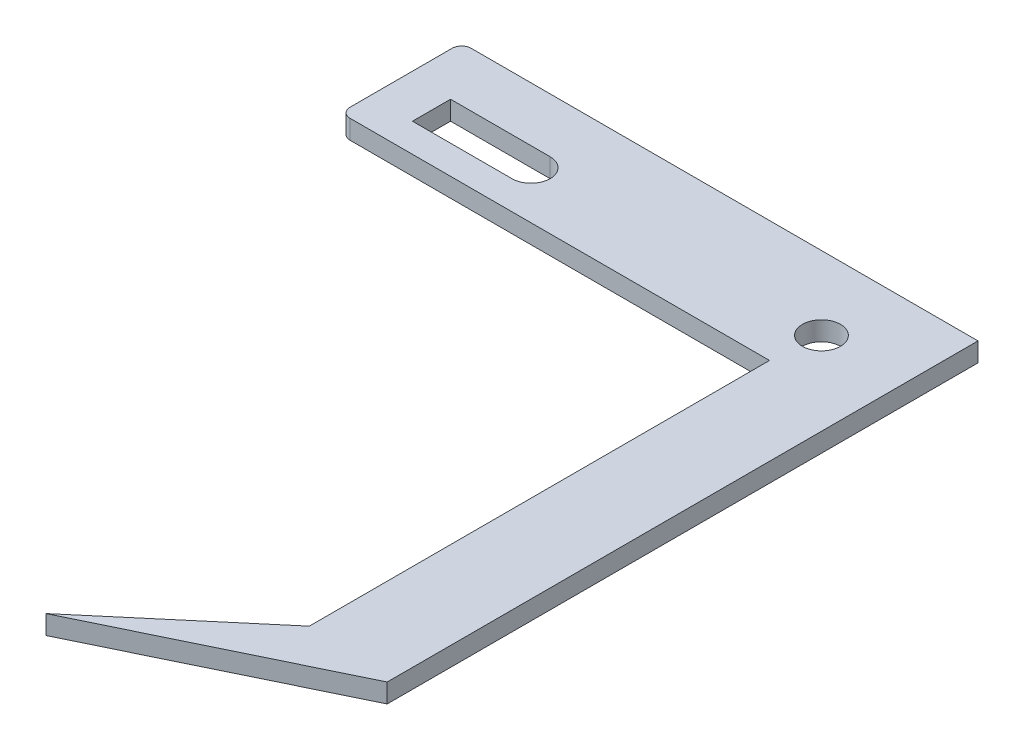
from build123d import *

# Parameters (mm, degrees)
SKETCH1_R           = 2
BOSS_EXTRUDE2_DEPTH = 2
CUT_EXTRUDE2_DEPTH  = 9
CUT_EXTRUDE3_DEPTH  = 9


with BuildPart() as part:
    # Sketch1 → Boss-Extrude2 (new body)
    with BuildSketch(Plane(origin=(0, 0, 0), x_dir=(1, 0, 0), z_dir=(0, 1, 0))):
        with BuildLine():
            Line((0, 48.412862342), (0, 37.692030173))
            ThreePointArc((0, 37.692030173), (0.292893219, 36.984923392), (1, 36.692030173))
            Line((1, 36.692030173), (31.48, 36.692030173))
            Line((31.48, 36.692030173), (43.036527631, 36.692030173))
            Line((43.036527631, 36.692030173), (43.036527631, -13.307969827))
            Line((43.036527631, -13.307969827), (38.310297741, -17.310739702))
            Line((38.310297741, -17.310739702), (34.253582629, -17.310739702))
            Line((34.253582629, -17.310739702), (36, -19.267392345))
            Line((36, -19.267392345), (30.071702425, -24.288225334))
            Line((30.071702425, -24.288225334), (54.200832168, -12.602889922))
            Line((54.200832168, -12.602889922), (54.200832168, 10.267562985))
            Line((54.200832168, 10.267562985), (54.200832168, 49.412862342))
            Line((54.200832168, 49.412862342), (41.48, 49.412862342))
            Line((41.48, 49.412862342), (1, 49.412862342))
            ThreePointArc((1, 49.412862342), (0.292893219, 49.119969123), (0, 48.412862342))
        make_face()
        with Locations((45.48, 41.700609081)):
            Circle(SKETCH1_R, mode=Mode.SUBTRACT)
        with BuildLine():
            Line((15, 43.700609081), (4.549516448, 43.700609081))
            Line((4.549516448, 43.700609081), (4.549516448, 39.700609081))
            Line((4.549516448, 39.700609081), (15, 39.700609081))
            ThreePointArc((15, 39.700609081), (17, 41.700609081), (15, 43.700609081))
        make_face(mode=Mode.SUBTRACT)
    extrude(amount=BOSS_EXTRUDE2_DEPTH)

    # Sketch6 → Cut-Extrude2 (cut)
    with BuildSketch(Plane(origin=(0, 2, 0), x_dir=(1, 0, 0), z_dir=(0, 1, 0))):
        Polygon((36, -19.267392345), (38.310297741, -17.310739702), (34.253582629, -17.310739702), align=None)
    extrude(amount=-CUT_EXTRUDE2_DEPTH, mode=Mode.SUBTRACT)

    # Sketch8 → Cut-Extrude3 (cut)
    with BuildSketch(Plane(origin=(0, 2, 0), x_dir=(1, 0, 0), z_dir=(0, 1, 0))):
        Polygon((43.036527631, 36.692030173), (45.036527631, 36.692030173), (45.036527631, -11.115496155), (45.036527631, -11.614116599), (43.036527631, -13.307969827), align=None)
    extrude(amount=-CUT_EXTRUDE3_DEPTH, mode=Mode.SUBTRACT)


solid = part.part
